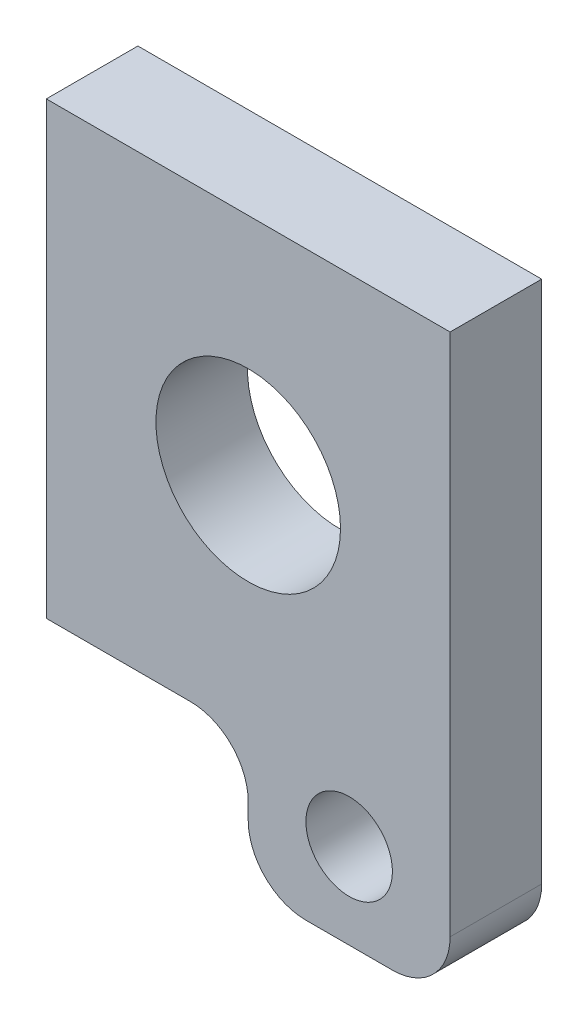
from build123d import *

# Parameters (mm, degrees)
SKETCH1_R           = 0.75
SKETCH1_R_2         = 1.6
BOSS_EXTRUDE1_DEPTH = 1.5875


with BuildPart() as part:
    # Sketch1 → Boss-Extrude1 (new body)
    with BuildSketch(Plane(origin=(0, 0, 0), x_dir=(-1, 0, 0), z_dir=(0, 0, -1))):
        with BuildLine():
            Line((3.5, -3.9), (3.5, 3.9))
            Line((3.5, 3.9), (-3.5, 3.9))
            Line((-3.5, 3.9), (-3.5, -5.18125))
            ThreePointArc((-3.5, -5.18125), (-3.207106781, -5.888356781), (-2.5, -6.18125))
            Line((-2.5, -6.18125), (-1, -6.18125))
            ThreePointArc((-1, -6.18125), (-0.292893219, -5.888356781), (0, -5.18125))
            Line((0, -5.18125), (0, -4.9))
            ThreePointArc((0, -4.9), (0.292893219, -4.192893219), (1, -3.9))
            Line((1, -3.9), (3.5, -3.9))
        make_face()
        with Locations((-1.75, -4.7)):
            Circle(SKETCH1_R, mode=Mode.SUBTRACT)
        Circle(SKETCH1_R_2, mode=Mode.SUBTRACT)
    extrude(amount=-BOSS_EXTRUDE1_DEPTH)


solid = part.part
